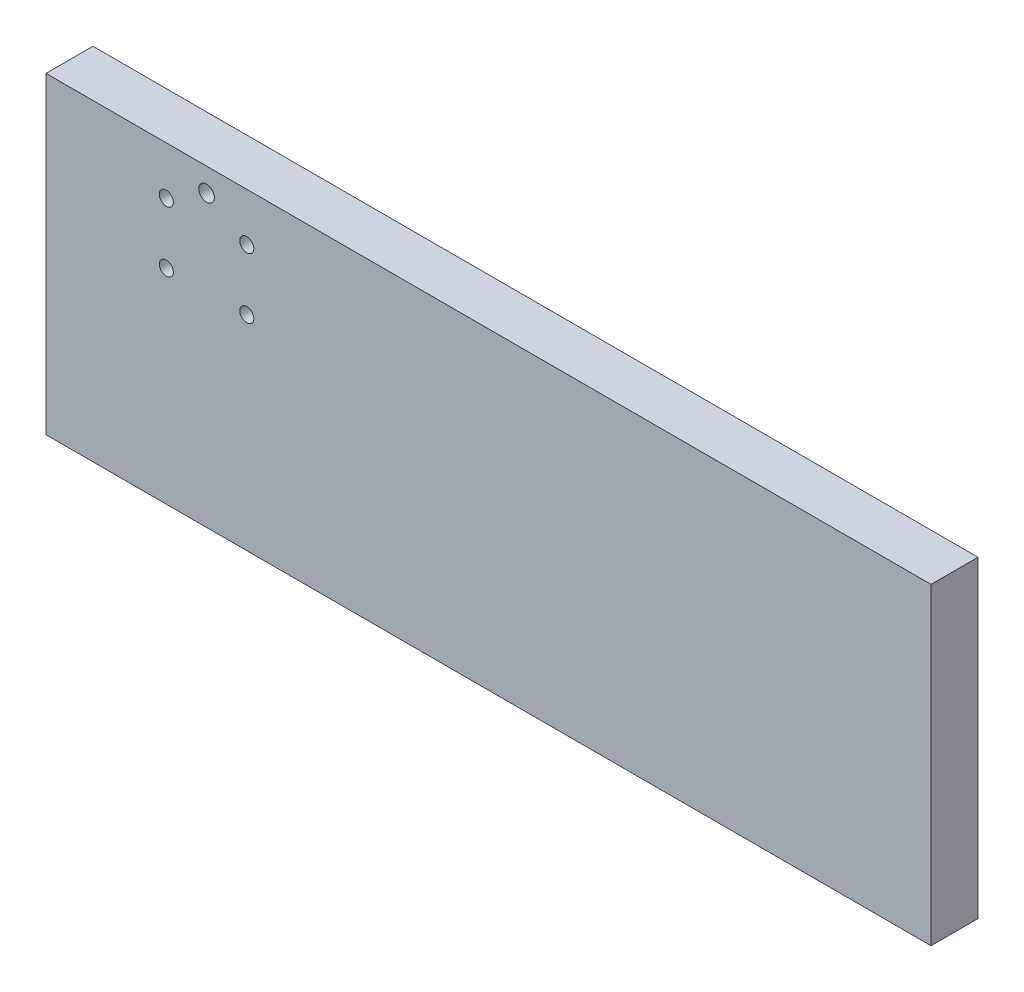
from build123d import *

# Parameters (mm, degrees)
SKETCH1_W           = 359.156
SKETCH1_H           = 127
BOSS_EXTRUDE1_DEPTH = 19.05
CUT_EXTRUDE1_REACH  = 21.05
SKETCH2_R           = 2.85115
CUT_EXTRUDE2_REACH  = 21.05
SKETCH3_R           = 3.175


with BuildPart() as part:
    # Sketch1 → Boss-Extrude1 (new body)
    with BuildSketch(Plane.XY):
        with Locations((179.578, 63.5)):
            Rectangle(SKETCH1_W, SKETCH1_H)
    extrude(amount=BOSS_EXTRUDE1_DEPTH)

    # Sketch2 → Cut-Extrude1 (cut, up to next)
    with BuildSketch(Plane.XY.offset(19.05), mode=Mode.PRIVATE) as cut_extrude1_sk1:
        with Locations((48.82515, 82.96275)):
            Circle(SKETCH2_R)
    cut_extrude1_tool1 = extrude(cut_extrude1_sk1.sketch, amount=-CUT_EXTRUDE1_REACH, mode=Mode.PRIVATE) & part.part
    add(cut_extrude1_tool1.solids().sort_by_distance((48.82515, 82.96275, 19.05))[0], mode=Mode.SUBTRACT)
    # Sketch2 → Cut-Extrude1 (cut, up to next)
    with BuildSketch(Plane.XY.offset(19.05), mode=Mode.PRIVATE) as cut_extrude1_sk2:
        with Locations((48.82515, 107.53725)):
            Circle(SKETCH2_R)
    cut_extrude1_tool2 = extrude(cut_extrude1_sk2.sketch, amount=-CUT_EXTRUDE1_REACH, mode=Mode.PRIVATE) & part.part
    add(cut_extrude1_tool2.solids().sort_by_distance((48.82515, 107.53725, 19.05))[0], mode=Mode.SUBTRACT)
    # Sketch2 → Cut-Extrude1 (cut, up to next)
    with BuildSketch(Plane.XY.offset(19.05), mode=Mode.PRIVATE) as cut_extrude1_sk3:
        with Locations((81.47685, 107.53725)):
            Circle(SKETCH2_R)
    cut_extrude1_tool3 = extrude(cut_extrude1_sk3.sketch, amount=-CUT_EXTRUDE1_REACH, mode=Mode.PRIVATE) & part.part
    add(cut_extrude1_tool3.solids().sort_by_distance((81.47685, 107.53725, 19.05))[0], mode=Mode.SUBTRACT)
    # Sketch2 → Cut-Extrude1 (cut, up to next)
    with BuildSketch(Plane.XY.offset(19.05), mode=Mode.PRIVATE) as cut_extrude1_sk4:
        with Locations((81.47685, 82.96275)):
            Circle(SKETCH2_R)
    cut_extrude1_tool4 = extrude(cut_extrude1_sk4.sketch, amount=-CUT_EXTRUDE1_REACH, mode=Mode.PRIVATE) & part.part
    add(cut_extrude1_tool4.solids().sort_by_distance((81.47685, 82.96275, 19.05))[0], mode=Mode.SUBTRACT)

    # Sketch3 → Cut-Extrude2 (cut, up to next)
    with BuildSketch(Plane(origin=(0, 0, 0), x_dir=(-1, 0, 0), z_dir=(0, 0, -1)), mode=Mode.PRIVATE) as cut_extrude2_sk1:
        with Locations((-65.151, 117.475)):
            Circle(SKETCH3_R)
    cut_extrude2_tool1 = extrude(cut_extrude2_sk1.sketch, amount=-CUT_EXTRUDE2_REACH, mode=Mode.PRIVATE) & part.part
    add(cut_extrude2_tool1.solids().sort_by_distance((65.151, 117.475, 0))[0], mode=Mode.SUBTRACT)


solid = part.part
